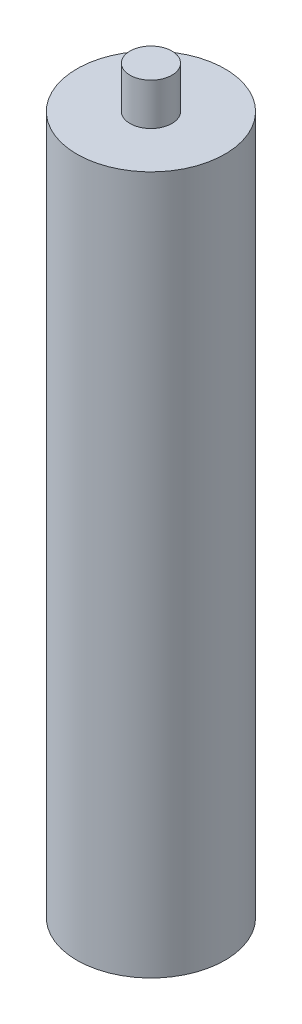
from build123d import *

# Parameters (mm, degrees)
SKETCH1_R           = 26.5
BOSS_EXTRUDE1_DEPTH = 250
SKETCH2_R           = 7.5
BOSS_EXTRUDE2_DEPTH = 15


with BuildPart() as part:
    # Sketch1 → Boss-Extrude1 (new body)
    with BuildSketch(Plane(origin=(0, 0, 0), x_dir=(1, 0, 0), z_dir=(0, 1, 0))):
        Circle(SKETCH1_R)
    extrude(amount=BOSS_EXTRUDE1_DEPTH)

    # Sketch2 → Boss-Extrude2 (add)
    with BuildSketch(Plane(origin=(0, 250, 0), x_dir=(1, 0, 0), z_dir=(0, 1, 0))):
        Circle(SKETCH2_R)
    extrude(amount=BOSS_EXTRUDE2_DEPTH)


solid = part.part
